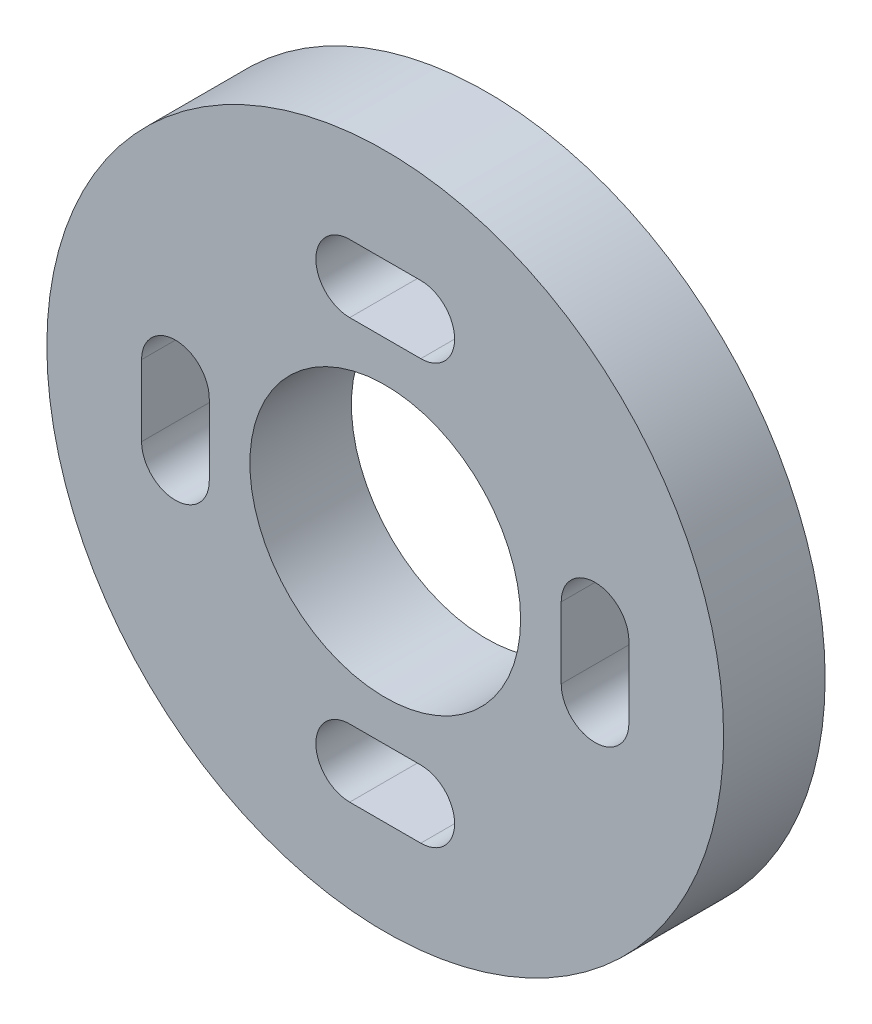
from build123d import *

# Parameters (mm, degrees)
SKETCH_1_R          = 10
EXTRUDE_1_DEPTH     = 3
SKETCH_2_R          = 4
CUT_EXTRUDE_1_DEPTH = 4


with BuildPart() as part:
    # 草圖1 → 填料-伸長1 (new body)
    with BuildSketch(Plane.XY):
        Circle(SKETCH_1_R)
    extrude(amount=EXTRUDE_1_DEPTH)

    # 草圖2 → 除料-伸長1 (cut)
    with BuildSketch(Plane.XY):
        Circle(SKETCH_2_R)
        with BuildLine():
            Line((-1.05, 7.2), (1.05, 7.2))
            ThreePointArc((1.05, 7.2), (2.05, 6.2), (1.05, 5.2))
            Line((1.05, 5.2), (-1.05, 5.2))
            ThreePointArc((-1.05, 5.2), (-2.05, 6.2), (-1.05, 7.2))
        make_face()
        with BuildLine():
            Line((-5.2, 1.05), (-5.2, -1.05))
            ThreePointArc((-5.2, -1.05), (-6.2, -2.05), (-7.2, -1.05))
            Line((-7.2, -1.05), (-7.2, 1.05))
            ThreePointArc((-7.2, 1.05), (-6.2, 2.05), (-5.2, 1.05))
        make_face()
        with BuildLine():
            Line((5.2, 1.05), (5.2, -1.05))
            ThreePointArc((5.2, -1.05), (6.2, -2.05), (7.2, -1.05))
            Line((7.2, -1.05), (7.2, 1.05))
            ThreePointArc((7.2, 1.05), (6.2, 2.05), (5.2, 1.05))
        make_face()
        with BuildLine():
            Line((-1.05, -7.2), (1.05, -7.2))
            ThreePointArc((1.05, -7.2), (2.05, -6.2), (1.05, -5.2))
            Line((1.05, -5.2), (-1.05, -5.2))
            ThreePointArc((-1.05, -5.2), (-2.05, -6.2), (-1.05, -7.2))
        make_face()
    extrude(amount=CUT_EXTRUDE_1_DEPTH, mode=Mode.SUBTRACT)


solid = part.part
